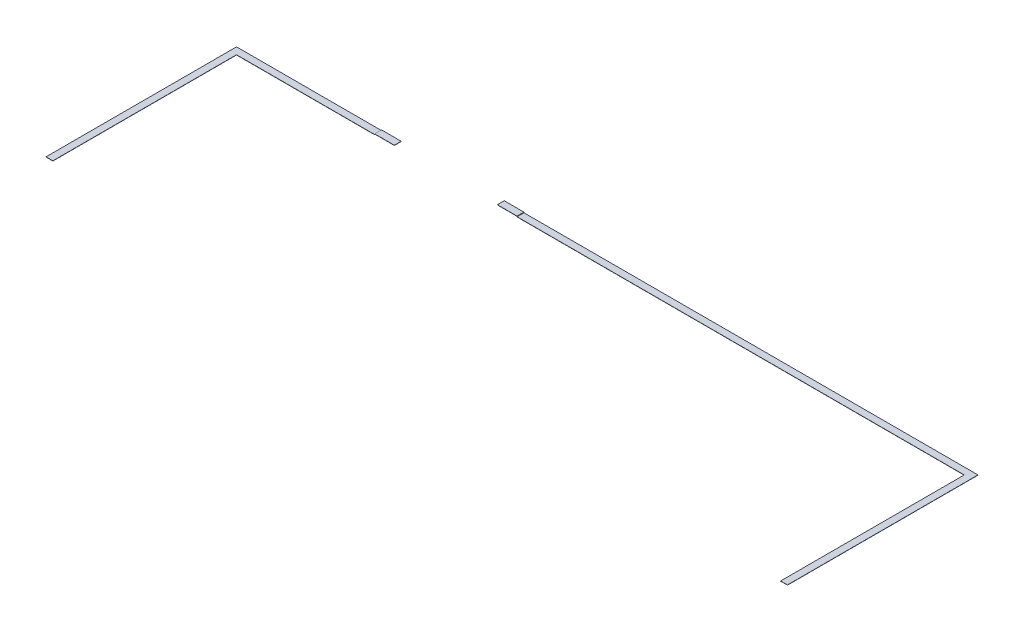
from build123d import *

# Parameters (mm, degrees)
BOSS_EXTRUDE1_DEPTH     = 1.5875
SKETCH2_W               = 1054.1
SKETCH2_H               = 50.8
CUT_EXTRUDE1_DEPTH      = 1
CUT_EXTRUDE1_DEPTH_BACK = 2.5875
SKETCH3_W               = 146.05
SKETCH3_H               = 50.8
BOSS_EXTRUDE2_DEPTH     = 1.5875
BOSS_EXTRUDE2_2_DEPTH   = 1.5875


with BuildPart() as part:
    # Sketch1 → Boss-Extrude1 (new body)
    with BuildSketch(Plane(origin=(0, 0, 0), x_dir=(1, 0, 0), z_dir=(0, 1, 0))):
        Polygon((0, 0), (0, 1409.7), (5486.4, 1409.7), (5486.4, 0), (5435.6, 0), (5435.6, 1358.9), (50.8, 1358.9), (50.8, 0), align=None)
    extrude(amount=BOSS_EXTRUDE1_DEPTH)

    # Sketch2 → Cut-Extrude1 (cut, two sides)
    with BuildSketch(Plane(origin=(0, 1.5875, 0), x_dir=(1, 0, 0), z_dir=(0, 1, 0))) as cut_extrude1_sk:
        with Locations((1599.6666, 1384.3)):
            Rectangle(SKETCH2_W, SKETCH2_H)
    extrude(amount=CUT_EXTRUDE1_DEPTH, mode=Mode.SUBTRACT)
    extrude(cut_extrude1_sk.sketch, amount=-CUT_EXTRUDE1_DEPTH_BACK, mode=Mode.SUBTRACT)


with BuildPart() as body_2:
    # Sketch3 → Boss-Extrude2 (new body)
    with BuildSketch(Plane(origin=(0, 4.2418, 0), x_dir=(-1, 0, 0), z_dir=(0, -1, 0))):
        with Locations((-1145.6416, 1384.3)):
            Rectangle(SKETCH3_W, SKETCH3_H)
    extrude(amount=-BOSS_EXTRUDE2_DEPTH)


with BuildPart() as body_3:
    # Sketch3 → Boss-Extrude2 2 (new body)
    with BuildSketch(Plane(origin=(0, 4.2418, 0), x_dir=(-1, 0, 0), z_dir=(0, -1, 0))):
        with Locations((-2053.6916, 1384.3)):
            Rectangle(SKETCH3_W, SKETCH3_H)
    extrude(amount=-BOSS_EXTRUDE2_2_DEPTH)


solid = Compound([part.part, body_2.part, body_3.part])
